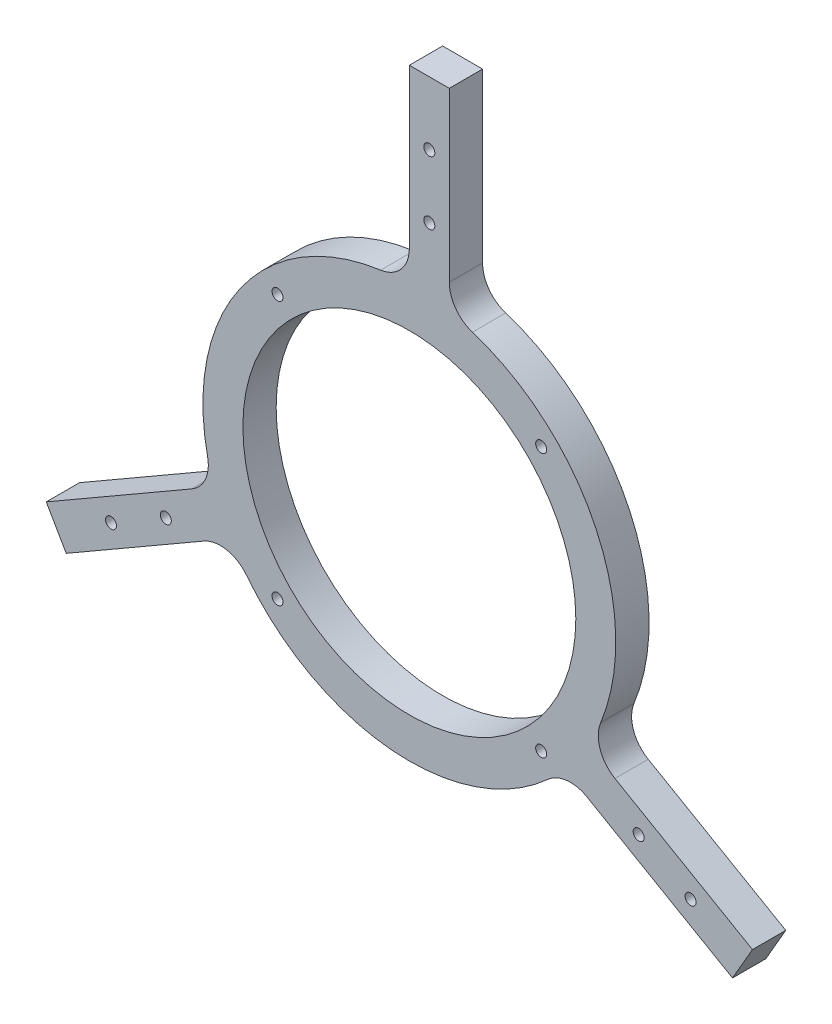
from build123d import *

# Parameters (mm, degrees)
SKETCH_1_R             = 50
EXTRUDE_1_DEPTH        = 10
HOLE_WIZARD_M4_1_D     = 3.3
HOLE_WIZARD_M4_1_DEPTH = 10.1
HOLE_WIZARD_M4_1_TIP   = 0.991420021
FILLET_1_R             = 10


with BuildPart() as part:
    # 草图1 → 凸台-拉伸1 (new body)
    with BuildSketch(Plane.XY):
        with BuildLine():
            Line((12, 60.827625303), (12, 119))
            Line((12, 119), (0, 119))
            Line((0, 119), (0, 62))
            ThreePointArc((0, 62), (-50.42486234, 36.073996979), (-58.678268764, -20.021507806))
            Line((-58.678268764, -20.021507806), (-109.05702305, -49.107695155))
            Line((-109.05702305, -49.107695155), (-103.05702305, -59.5))
            Line((-103.05702305, -59.5), (-53.693575035, -31))
            ThreePointArc((-53.693575035, -31), (-6.02856663, -61.706210258), (46.678268764, -40.806117497))
            Line((46.678268764, -40.806117497), (97.05702305, -69.892304845))
            Line((97.05702305, -69.892304845), (103.05702305, -59.5))
            Line((103.05702305, -59.5), (53.693575035, -31))
            ThreePointArc((53.693575035, -31), (56.453428969, 25.632213279), (12, 60.827625303))
        make_face()
        Circle(SKETCH_1_R, mode=Mode.SUBTRACT)
    extrude(amount=EXTRUDE_1_DEPTH)

    # M4 螺纹孔1
    with Locations(Plane.XY.offset(10)):
        with Locations((-39.597979746, 39.597979746), (-39.597979746, -39.597979746), (39.597979746, -39.597979746), (39.597979746, 39.597979746), (-89.602540378, -44.803847577), (-73.148057707, -35.303847577), (84.468565782, -55.696152423), (68.880108514, -46.696152423), (6, 81), (6, 100)):
            Hole(HOLE_WIZARD_M4_1_D / 2, depth=HOLE_WIZARD_M4_1_DEPTH)
            with Locations((0, 0, -(HOLE_WIZARD_M4_1_DEPTH + HOLE_WIZARD_M4_1_TIP / 2))):  # 118° drill point
                Cone(0, HOLE_WIZARD_M4_1_D / 2, HOLE_WIZARD_M4_1_TIP, mode=Mode.SUBTRACT)

    # 圆角1
    fillet_1_edges = [part.edges().sort_by_distance(p)[0] for p in [
        (-58.678268764, -20.021507806, 5),
        (0, 62, 5),
        (12, 60.827625303, 5),
        (53.693575035, -31, 5),
        (46.678268764, -40.806117497, 5),
        (-53.693575035, -31, 5),
    ]]
    fillet(fillet_1_edges, radius=FILLET_1_R)


solid = part.part
